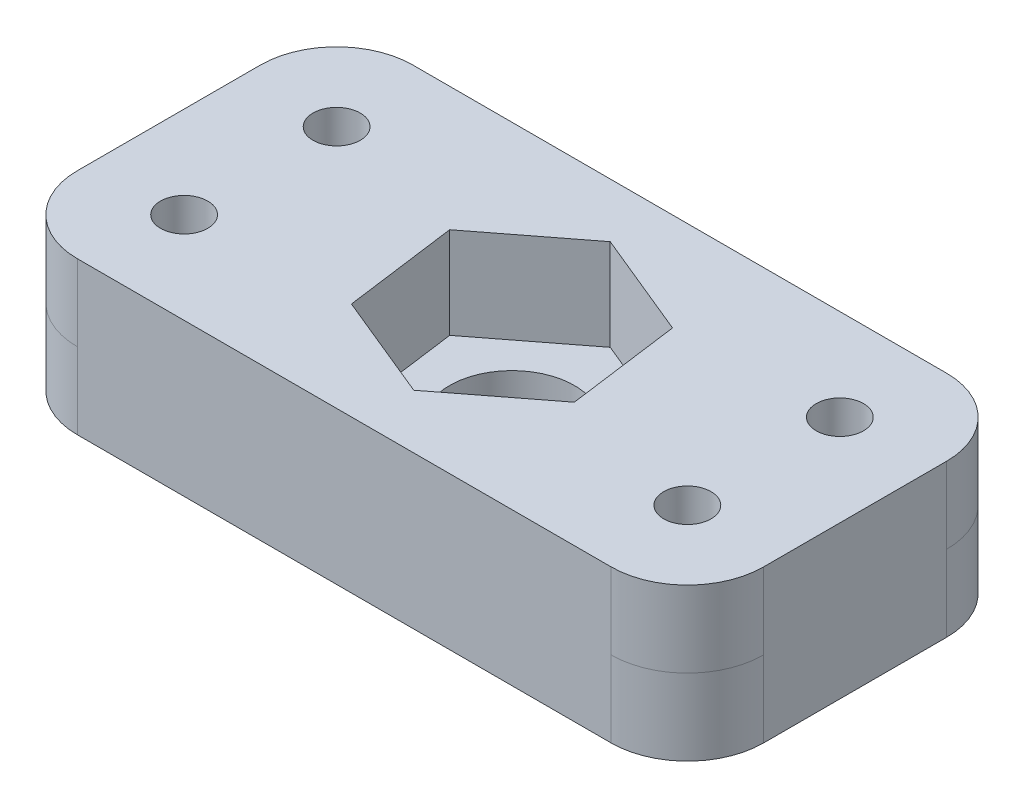
from build123d import *

# Parameters (mm, degrees)
CROQUIS1_R              = 10
CROQUIS1_R_2            = 3.5
EXTRUIR1_DEPTH          = 12
CROQUIS2_W              = 45
CROQUIS2_H              = 22
SALIENTE_EXTRUIR1_DEPTH = 5
REDONDEO1_R             = 5
REDONDEO2_R             = 5
REDONDEO3_R             = 5
REDONDEO4_R             = 5
CROQUIS3_R              = 4.1
CORTAR_EXTRUIR1_DEPTH   = 45
CROQUIS4_R              = 1.55
CORTAR_EXTRUIR2_DEPTH   = 45
CROQUIS7_W              = 22.113905464
CROQUIS7_H              = 24
CORTAR_EXTRUIR4_DEPTH   = 70
CROQUIS8_W              = 45
CROQUIS8_H              = 22
SALIENTE_EXTRUIR2_DEPTH = 5
REDONDEO5_R             = 5
REDONDEO6_R             = 5
REDONDEO7_R             = 5
REDONDEO8_R             = 5
CROQUIS9_R              = 1.55
CROQUIS9_R_2            = 4.1
CORTAR_EXTRUIR5_DEPTH   = 15
CORTAR_EXTRUIR7_DEPTH   = 6


with BuildPart() as part:
    # Croquis1 → Extruir1 (new body)
    with BuildSketch(Plane(origin=(0, 0, 0), x_dir=(1, 0, 0), z_dir=(0, 1, 0))):
        Circle(CROQUIS1_R)
        Circle(CROQUIS1_R_2, mode=Mode.SUBTRACT)
    extrude(amount=EXTRUIR1_DEPTH)

    # Croquis2 → Saliente-Extruir1 (add)
    with BuildSketch(Plane(origin=(0, 12, 0), x_dir=(1, 0, 0), z_dir=(0, 1, 0))):
        Rectangle(CROQUIS2_W, CROQUIS2_H)
    extrude(amount=SALIENTE_EXTRUIR1_DEPTH)

    # Redondeo1
    redondeo1_edges = [part.edges().sort_by_distance(p)[0] for p in [
        (22.5, 14.5, -11),
    ]]
    fillet(redondeo1_edges, radius=REDONDEO1_R)

    # Redondeo2
    redondeo2_edges = [part.edges().sort_by_distance(p)[0] for p in [
        (22.5, 14.5, 11),
    ]]
    fillet(redondeo2_edges, radius=REDONDEO2_R)

    # Redondeo3
    redondeo3_edges = [part.edges().sort_by_distance(p)[0] for p in [
        (-22.5, 14.5, 11),
    ]]
    fillet(redondeo3_edges, radius=REDONDEO3_R)

    # Redondeo4
    redondeo4_edges = [part.edges().sort_by_distance(p)[0] for p in [
        (-22.5, 14.5, -11),
    ]]
    fillet(redondeo4_edges, radius=REDONDEO4_R)

    # Croquis3 → Cortar-Extruir1 (cut)
    with BuildSketch(Plane.XZ):
        Circle(CROQUIS3_R)
    extrude(amount=-CORTAR_EXTRUIR1_DEPTH, mode=Mode.SUBTRACT)

    # Croquis4 → Cortar-Extruir2 (cut)
    with BuildSketch(Plane.XZ.offset(-12)):
        with Locations((-16.5, 5)):
            Circle(CROQUIS4_R)
        with Locations((-16.5, -5)):
            Circle(CROQUIS4_R)
        with Locations((16.5, 5)):
            Circle(CROQUIS4_R)
        with Locations((16.5, -5)):
            Circle(CROQUIS4_R)
    extrude(amount=-CORTAR_EXTRUIR2_DEPTH, mode=Mode.SUBTRACT)

    # Croquis7 → Cortar-Extruir4 (cut)
    with BuildSketch(Plane.XY.offset(11)):
        Rectangle(CROQUIS7_W, CROQUIS7_H)
    extrude(amount=-CORTAR_EXTRUIR4_DEPTH, mode=Mode.SUBTRACT)

    # Croquis8 → Saliente-Extruir2 (add)
    with BuildSketch(Plane.XZ.offset(-12)):
        Rectangle(CROQUIS8_W, CROQUIS8_H)
    extrude(amount=SALIENTE_EXTRUIR2_DEPTH)

    # Redondeo5
    redondeo5_edges = [part.edges().sort_by_distance(p)[0] for p in [
        (-22.5, 9.5, -11),
    ]]
    fillet(redondeo5_edges, radius=REDONDEO5_R)

    # Redondeo6
    redondeo6_edges = [part.edges().sort_by_distance(p)[0] for p in [
        (22.5, 9.5, -11),
    ]]
    fillet(redondeo6_edges, radius=REDONDEO6_R)

    # Redondeo7
    redondeo7_edges = [part.edges().sort_by_distance(p)[0] for p in [
        (22.5, 9.5, 11),
    ]]
    fillet(redondeo7_edges, radius=REDONDEO7_R)

    # Redondeo8
    redondeo8_edges = [part.edges().sort_by_distance(p)[0] for p in [
        (-22.5, 9.5, 11),
    ]]
    fillet(redondeo8_edges, radius=REDONDEO8_R)

    # Croquis9 → Cortar-Extruir5 (cut)
    with BuildSketch(Plane(origin=(0, 17, 0), x_dir=(1, 0, 0), z_dir=(0, 1, 0))):
        with Locations((-16.5, -5)):
            Circle(CROQUIS9_R)
        with Locations((-16.5, 5)):
            Circle(CROQUIS9_R)
        with Locations((16.5, -5)):
            Circle(CROQUIS9_R)
        with Locations((16.5, 5)):
            Circle(CROQUIS9_R)
        Circle(CROQUIS9_R_2)
    extrude(amount=-CORTAR_EXTRUIR5_DEPTH, mode=Mode.SUBTRACT)

    # Croquis10 → Cortar-Extruir7 (cut)
    with BuildSketch(Plane(origin=(0, 17, 0), x_dir=(1, 0, 0), z_dir=(0, 1, 0))):
        Polygon((6.941222487, -2.855304489), (5.943377466, 4.583622763), (-0.997845021, 7.438927251), (-6.941222487, 2.855304489), (-5.943377466, -4.583622763), (0.997845021, -7.438927251), align=None)
    extrude(amount=-CORTAR_EXTRUIR7_DEPTH, mode=Mode.SUBTRACT)


solid = part.part
